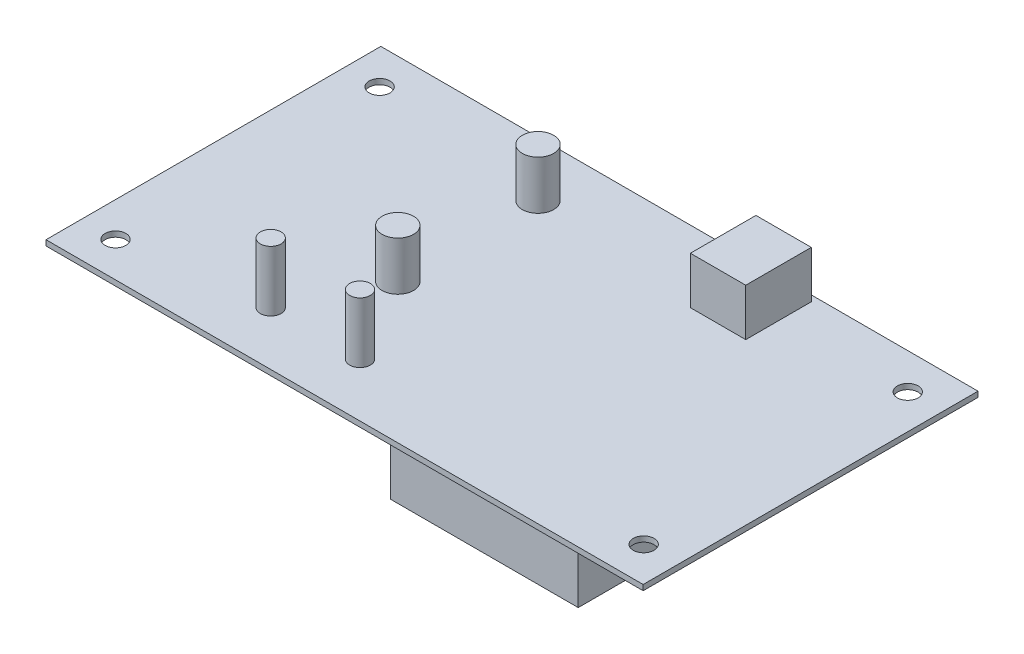
from build123d import *

# Parameters (mm, degrees)
SKETCH1_W           = 169.8625
SKETCH1_H           = 95.25
BOSS_EXTRUDE1_DEPTH = 1.5494
SKETCH2_W           = 15.748
SKETCH2_H           = 18.6436
BOSS_EXTRUDE2_DEPTH = 13.4112
SKETCH3_R           = 4.4704
BOSS_EXTRUDE3_DEPTH = 13.843
SKETCH4_R           = 2.95275
BOSS_EXTRUDE4_DEPTH = 17.1704
SKETCH5_W           = 53.34
SKETCH5_H           = 68.58
BOSS_EXTRUDE5_DEPTH = 14.478
SKETCH6_R           = 2.95275
CUT_EXTRUDE1_DEPTH  = 14.478


with BuildPart() as part:
    # Sketch1 → Boss-Extrude1 (new body)
    with BuildSketch(Plane(origin=(0, 0, 0), x_dir=(1, 0, 0), z_dir=(0, 1, 0))):
        with Locations((84.93125, 47.625)):
            Rectangle(SKETCH1_W, SKETCH1_H)
    extrude(amount=BOSS_EXTRUDE1_DEPTH)

    # Sketch2 → Boss-Extrude2 (add)
    with BuildSketch(Plane(origin=(0, 1.5494, 0), x_dir=(1, 0, 0), z_dir=(0, 1, 0))):
        with Locations((116.2685, 84.2264)):
            Rectangle(SKETCH2_W, SKETCH2_H)
    extrude(amount=BOSS_EXTRUDE2_DEPTH)

    # Sketch3 → Boss-Extrude3 (add)
    with BuildSketch(Plane(origin=(0, 1.5494, 0), x_dir=(1, 0, 0), z_dir=(0, 1, 0))):
        with Locations((60.325, 79.629)):
            Circle(SKETCH3_R)
        with Locations((60.325, 39.751)):
            Circle(SKETCH3_R)
    extrude(amount=BOSS_EXTRUDE3_DEPTH)

    # Sketch4 → Boss-Extrude4 (add)
    with BuildSketch(Plane(origin=(0, 1.5494, 0), x_dir=(1, 0, 0), z_dir=(0, 1, 0))):
        with Locations((48.6791, 15.24)):
            Circle(SKETCH4_R)
        with Locations((74.0791, 15.24)):
            Circle(SKETCH4_R)
    extrude(amount=BOSS_EXTRUDE4_DEPTH)

    # Sketch5 → Boss-Extrude5 (add)
    with BuildSketch(Plane(origin=(0, 0, 0), x_dir=(-1, 0, 0), z_dir=(0, -1, 0))):
        with Locations((-123.6345, 35.3822)):
            Rectangle(SKETCH5_W, SKETCH5_H)
    extrude(amount=BOSS_EXTRUDE5_DEPTH)

    # Sketch6 → Cut-Extrude1 (cut)
    with BuildSketch(Plane(origin=(0, 1.5494, 0), x_dir=(1, 0, 0), z_dir=(0, 1, 0))):
        with Locations((9.81075, 85.08365)):
            Circle(SKETCH6_R)
        with Locations((160.05175, 85.08365)):
            Circle(SKETCH6_R)
        with Locations((160.05175, 9.96315)):
            Circle(SKETCH6_R)
        with Locations((9.81075, 9.96315)):
            Circle(SKETCH6_R)
    extrude(amount=-CUT_EXTRUDE1_DEPTH, mode=Mode.SUBTRACT)


solid = part.part
